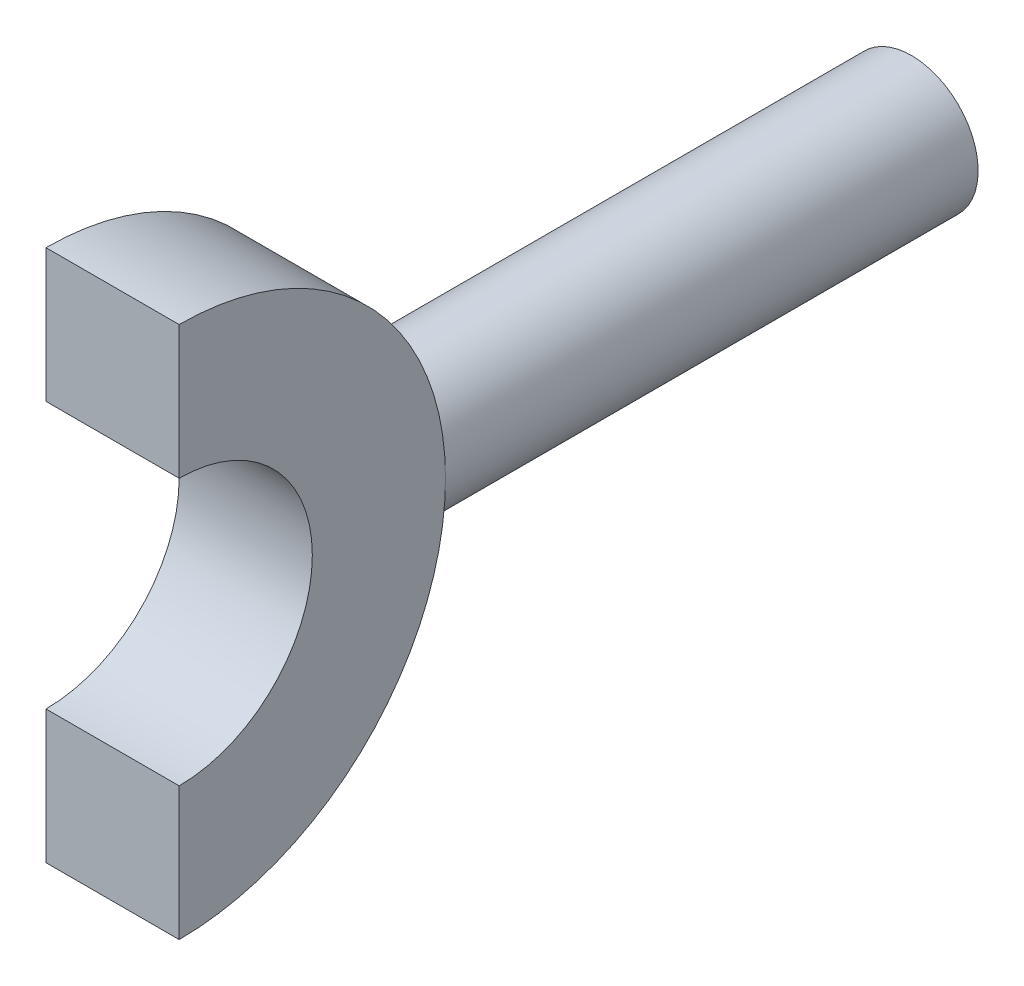
from build123d import *

# Parameters (mm, degrees)
SKETCH2_R               = 10
BOSS_EXTRUDE1_DEPTH     = 2.5
CUT_EXTRUDE1_DEPTH      = 1
CUT_EXTRUDE1_DEPTH_BACK = 6
BOSS_EXTRUDE2_REACH     = 32
SKETCH4_R               = 2.5


with BuildPart() as part:
    # Sketch2 → Boss-Extrude1 (new body, symmetric)
    with BuildSketch(Plane(origin=(0, 0, 0), x_dir=(0, 0, -1), z_dir=(1, 0, 0))):
        Circle(SKETCH2_R)
    extrude(amount=BOSS_EXTRUDE1_DEPTH, both=True)

    # Sketch3 → Cut-Extrude1 (cut, two sides)
    with BuildSketch(Plane(origin=(2.5, 0, 0), x_dir=(0, 0, -1), z_dir=(1, 0, 0))) as cut_extrude1_sk:
        with BuildLine():
            Line((0, 5), (0, 10))
            ThreePointArc((0, 10), (-10, 0), (0, -10))
            Line((0, -10), (0, -5))
            ThreePointArc((0, -5), (5, 0), (0, 5))
        make_face()
    extrude(amount=CUT_EXTRUDE1_DEPTH, mode=Mode.SUBTRACT)
    extrude(cut_extrude1_sk.sketch, amount=-CUT_EXTRUDE1_DEPTH_BACK, mode=Mode.SUBTRACT)

    # Sketch4 → Boss-Extrude2 (add, up to next)
    with BuildSketch(Plane(origin=(0, 0, -30), x_dir=(-1, 0, 0), z_dir=(0, 0, -1)), mode=Mode.PRIVATE) as boss_extrude2_sk1:
        Circle(SKETCH4_R)
    boss_extrude2_tool1 = extrude(boss_extrude2_sk1.sketch, amount=-BOSS_EXTRUDE2_REACH, mode=Mode.PRIVATE) - part.part
    add(boss_extrude2_tool1.solids().sort_by_distance((0, 0, -30))[0])


solid = part.part
